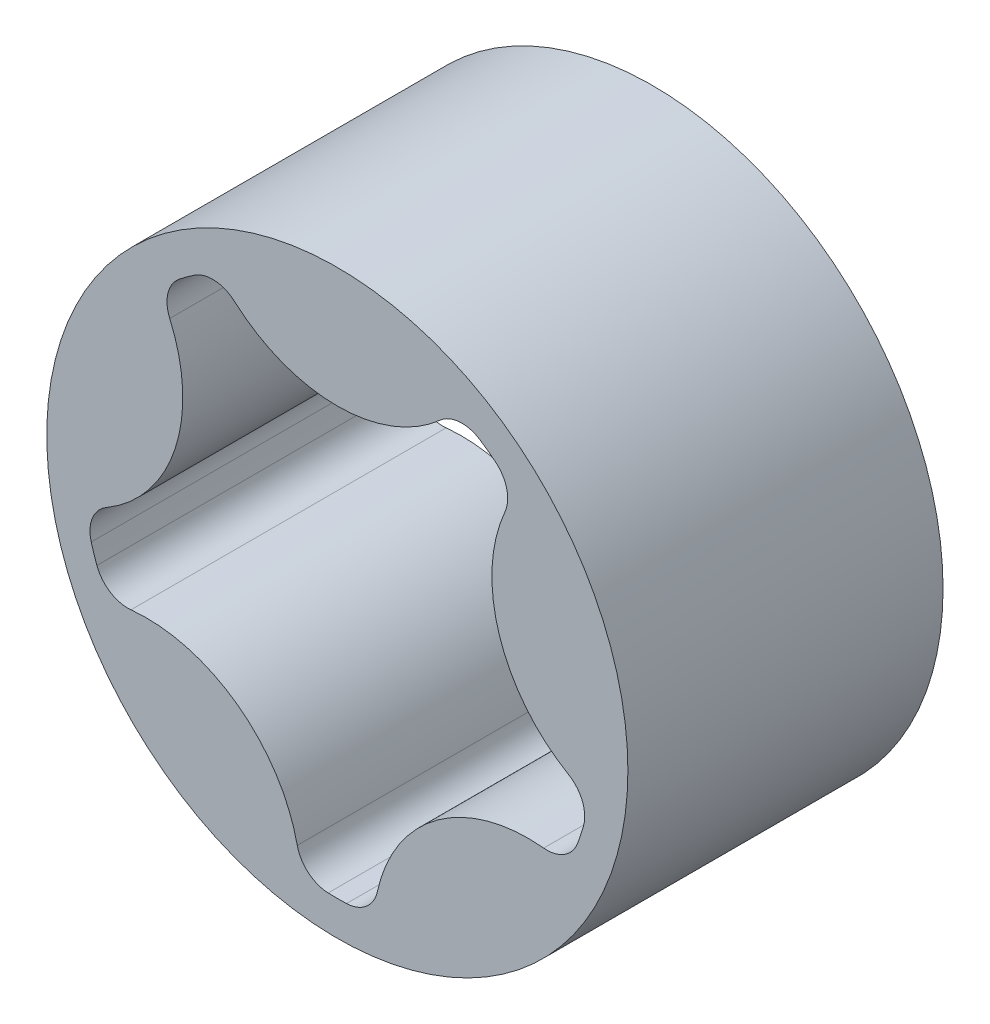
from build123d import *

# Parameters (mm, degrees)
SKETCH1_R          = 20.2565
BASE_EXTRUDE_DEPTH = 21.971


with BuildPart() as part:
    # Sketch1 → Base-Extrude (new body)
    with BuildSketch(Plane.XY):
        Circle(SKETCH1_R)
        with BuildLine():
            ThreePointArc((-9.962871848, 14.803096865), (-10.488146149, 14.435694739), (-10.999885021, 14.049662693))
            ThreePointArc((-10.999885021, 14.049662693), (-11.807615401, 12.807242878), (-11.683709562, 11.330529398))
            ThreePointArc((-11.683709562, 11.330529398), (-11.301861211, 3.672197312), (-16.112237674, -2.299078665))
            ThreePointArc((-16.112237674, -2.299078665), (-17.080470009, -3.420934942), (-17.157278449, -4.900845691))
            ThreePointArc((-17.157278449, -4.900845691), (-16.970176949, -5.513944739), (-16.761174663, -6.11992779))
            ThreePointArc((-16.761174663, -6.11992779), (-15.829165617, -7.272053868), (-14.386438629, -7.610541975))
            ThreePointArc((-14.386438629, -7.610541975), (-6.984934365, -9.613937375), (-2.792401513, -16.034103011))
            ThreePointArc((-2.792401513, -16.034103011), (-2.024653036, -17.301619337), (-0.640909388, -17.831986076))
            ThreePointArc((-0.640909388, -17.831986076), (0, -17.8435), (0.640909388, -17.831986076))
            ThreePointArc((0.640909388, -17.831986076), (2.024653036, -17.301619337), (2.792401513, -16.034103011))
            ThreePointArc((2.792401513, -16.034103011), (6.984934365, -9.613937375), (14.386438629, -7.610541975))
            ThreePointArc((14.386438629, -7.610541975), (15.829165617, -7.272053868), (16.761174663, -6.11992779))
            ThreePointArc((16.761174663, -6.11992779), (16.970176949, -5.513944739), (17.157278449, -4.900845691))
            ThreePointArc((17.157278449, -4.900845691), (17.080470009, -3.420934942), (16.112237674, -2.299078665))
            ThreePointArc((16.112237674, -2.299078665), (11.301861211, 3.672197312), (11.683709562, 11.330529398))
            ThreePointArc((11.683709562, 11.330529398), (11.807615401, 12.807242878), (10.999885021, 14.049662693))
            ThreePointArc((10.999885021, 14.049662693), (10.488146149, 14.435694739), (9.962871848, 14.803096865))
            ThreePointArc((9.962871848, 14.803096865), (8.531657973, 15.187365269), (7.165509005, 14.613194253))
            ThreePointArc((7.165509005, 14.613194253), (0, 11.883480127), (-7.165509005, 14.613194253))
            ThreePointArc((-7.165509005, 14.613194253), (-8.531657973, 15.187365269), (-9.962871848, 14.803096865))
        make_face(mode=Mode.SUBTRACT)
    extrude(amount=BASE_EXTRUDE_DEPTH)


solid = part.part
